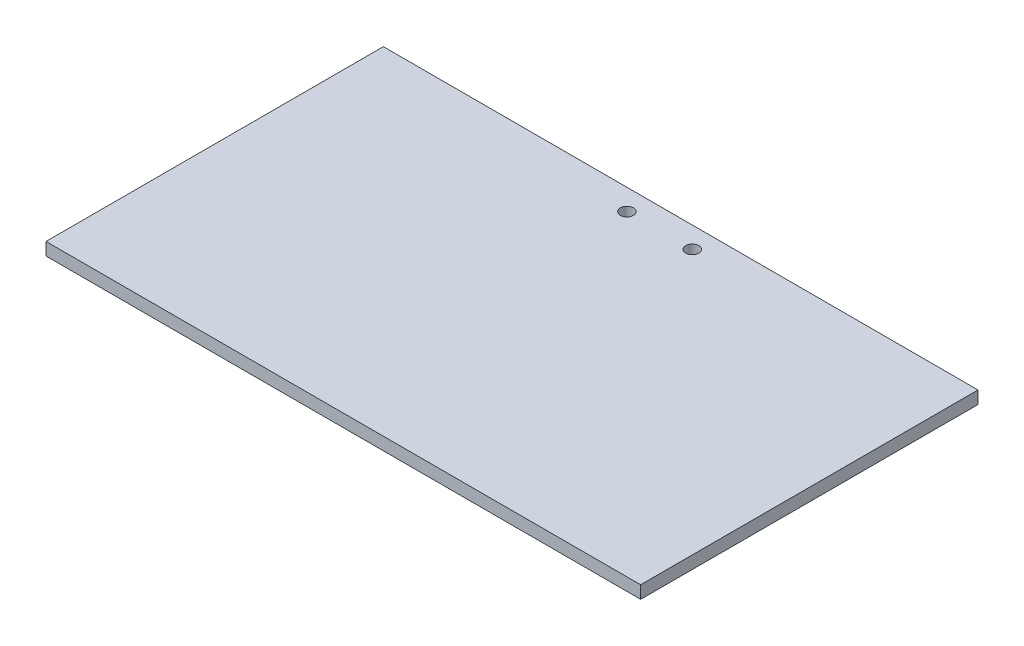
from build123d import *

# Parameters (mm, degrees)
SKETCH_1_W          = 141
SKETCH_1_H          = 80
EXTRUDE_1_DEPTH     = 3
SKETCH_2_R          = 1.55
CUT_EXTRUDE_1_DEPTH = 3


with BuildPart() as part:
    # ｽｹｯﾁ1 → ﾎﾞｽ - 押し出し1 (new body)
    with BuildSketch(Plane(origin=(0, 0, 0), x_dir=(1, 0, 0), z_dir=(0, 1, 0))):
        Rectangle(SKETCH_1_W, SKETCH_1_H)
    extrude(amount=EXTRUDE_1_DEPTH)

    # ｽｹｯﾁ2 → ｶｯﾄ - 押し出し1 (cut)
    with BuildSketch(Plane(origin=(0, 3, 0), x_dir=(1, 0, 0), z_dir=(0, 1, 0))):
        with Locations(Location((-7.75, 35, 0), (0, 0, 270))):  # turned: the seam where the file's is
            Circle(SKETCH_2_R)
        with Locations(Location((7.75, 35, 0), (0, 0, 270))):  # turned: the seam where the file's is
            Circle(SKETCH_2_R)
    extrude(amount=-CUT_EXTRUDE_1_DEPTH, mode=Mode.SUBTRACT)


solid = part.part
